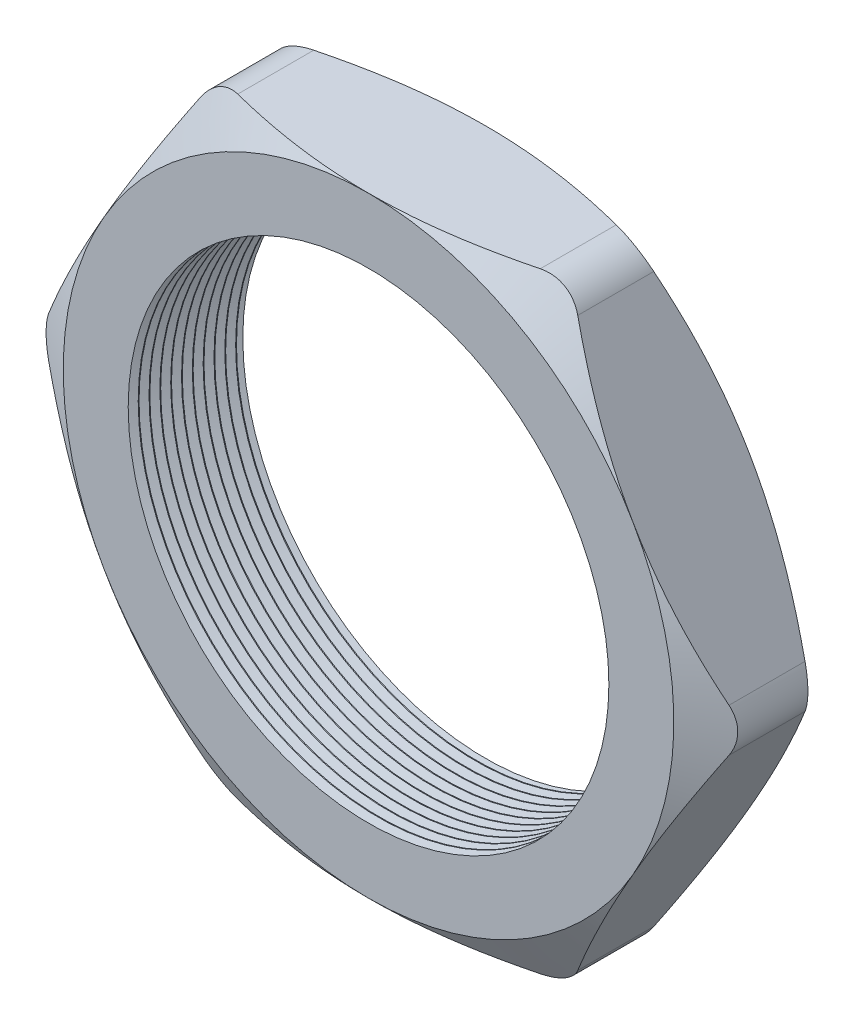
from build123d import *

# Parameters (mm, degrees)
SKETCH1_R          = 14.097
EXTRUDE1_DEPTH     = 6.858
SKETCH2_OUTSIDE_W  = 81.602
SKETCH2_OUTSIDE_H  = 76.062
SKETCH2_OUTSIDE_R  = 17.907
CUT_EXTRUDE1_DEPTH = 7.858
CUT_EXTRUDE1_DRAFT = -60
SKETCH3_OUTSIDE_W  = 81.602
SKETCH3_OUTSIDE_H  = 76.062
SKETCH3_OUTSIDE_R  = 17.907
CUT_EXTRUDE2_DEPTH = 7.858
CUT_EXTRUDE2_DRAFT = -60
FILLET1_R          = 2.54
LPATTERN1_COUNT    = 11
LPATTERN1_PITCH    = 0.635


with BuildPart() as part:
    # Sketch1 → Extrude1 (new body)
    with BuildSketch(Plane.XY):
        Polygon((-20.677222541, 0), (-10.33861127, -17.907), (10.33861127, -17.907), (20.677222541, 0), (10.33861127, 17.907), (-10.33861127, 17.907), align=None)
        Circle(SKETCH1_R, mode=Mode.SUBTRACT)
    extrude(amount=EXTRUDE1_DEPTH)


with BuildPart() as cut_extrude1_tool:
    # Sketch2 outside → Cut-Extrude1 (with draft: the straight prism first)
    with BuildSketch(Plane.XY.offset(6.858)):
        Rectangle(SKETCH2_OUTSIDE_W, SKETCH2_OUTSIDE_H)
        Circle(SKETCH2_OUTSIDE_R, mode=Mode.SUBTRACT)
    extrude(amount=-CUT_EXTRUDE1_DEPTH)
    # Cut-Extrude1: the draft: its side faces are tilted about the plane it starts from
    cut_extrude1_sides = [cut_extrude1_tool.faces().sort_by_distance(p)[0] for p in [
        (0, -38.031, 2.929),
        (40.801, 0, 2.929),
        (0, 38.031, 2.929),
        (-40.801, 0, 2.929),
        (-17.907, 0, 2.929),
    ]]
    draft(cut_extrude1_sides, Plane.XY.offset(6.858), CUT_EXTRUDE1_DRAFT)


with BuildPart() as part_1:
    add(part.part)

    # Cut-Extrude1: cut by cut_extrude1_tool
    add(cut_extrude1_tool.part, mode=Mode.SUBTRACT)


with BuildPart() as cut_extrude2_tool:
    # Sketch3 outside → Cut-Extrude2 (with draft: the straight prism first)
    with BuildSketch(Plane(origin=(0, 0, 0), x_dir=(-1, 0, 0), z_dir=(0, 0, -1))):
        Rectangle(SKETCH3_OUTSIDE_W, SKETCH3_OUTSIDE_H)
        Circle(SKETCH3_OUTSIDE_R, mode=Mode.SUBTRACT)
    extrude(amount=-CUT_EXTRUDE2_DEPTH)
    # Cut-Extrude2: the draft: its side faces are tilted about the plane it starts from
    cut_extrude2_sides = [cut_extrude2_tool.faces().sort_by_distance(p)[0] for p in [
        (0, -38.031, 3.929),
        (-40.801, 0, 3.929),
        (0, 38.031, 3.929),
        (40.801, 0, 3.929),
        (17.907, 0, 3.929),
    ]]
    draft(cut_extrude2_sides, Plane(origin=(0, 0, 0), x_dir=(-1, 0, 0), z_dir=(0, 0, -1)), CUT_EXTRUDE2_DRAFT)


with BuildPart() as part_2:
    add(part_1.part)

    # Cut-Extrude2: cut by cut_extrude2_tool
    add(cut_extrude2_tool.part, mode=Mode.SUBTRACT)

    # Fillet1
    fillet1_edges = [part_2.edges().sort_by_distance(p)[0] for p in [
        (20.677222541, 0, 3.429),
        (10.33861127, -17.907, 3.429),
        (-10.33861127, -17.907, 3.429),
        (-20.677222541, 0, 3.429),
        (-10.33861127, 17.907, 3.429),
        (10.33861127, 17.907, 3.429),
    ]]
    fillet(fillet1_edges, radius=FILLET1_R)

    # Sketch4 → Cut-Revolve1 (revolve, cut)
    with BuildSketch(Plane(origin=(0, 0, 0), x_dir=(1, 0, 0), z_dir=(0, 1, 0)), mode=Mode.PRIVATE) as cut_revolve1_sk:
        Polygon((-14.097, -6.858), (-14.097, -6.271412127), (-14.605, -6.564706063), align=None)
    cut_revolve1 = revolve(cut_revolve1_sk.sketch.rotate(Axis((0, 0, 0), (0, 0, 1)), 180), axis=Axis((0, 0, 0), (0, 0, 1)), mode=Mode.SUBTRACT)  # turned: the seam where the file's is

    # LPattern1: Cut-Revolve1 ×11
    with Locations(*[(0, 0, -i * LPATTERN1_PITCH) for i in range(1, LPATTERN1_COUNT)]):
        add(cut_revolve1, mode=Mode.SUBTRACT)


solid = part_2.part
